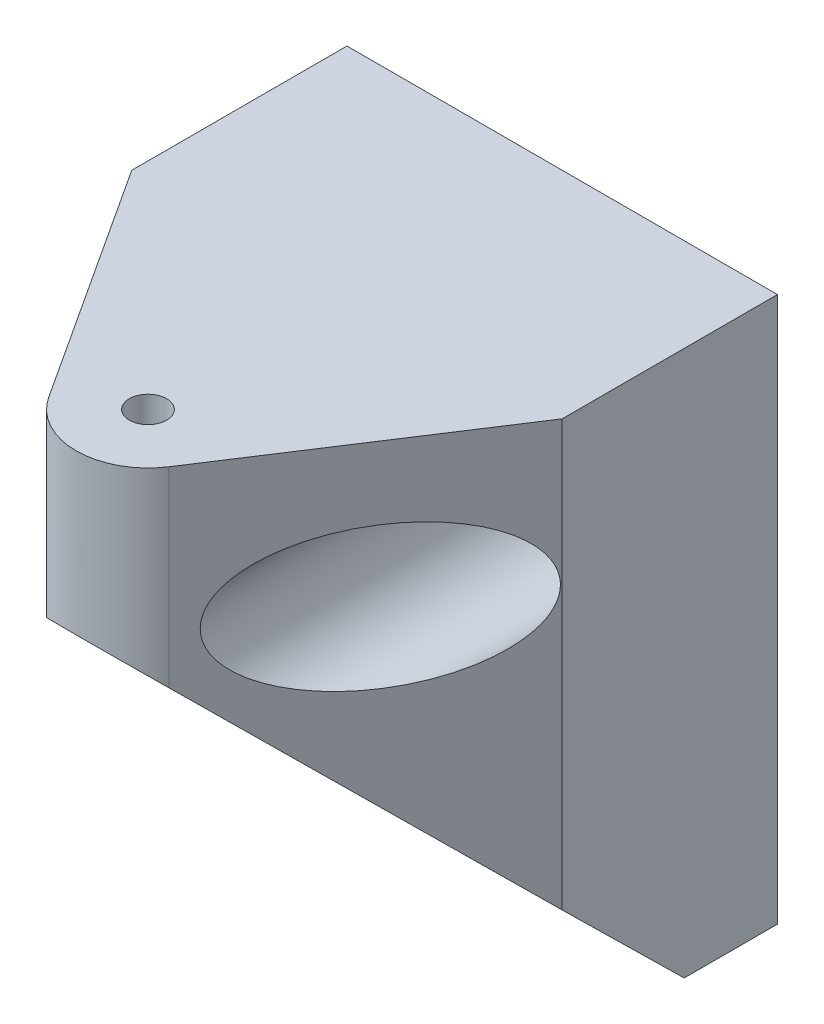
from build123d import *

# Parameters (mm, degrees)
BOSS_EXTRUDE1_DEPTH = 30
CUT_EXTRUDE1_REACH  = 37
SKETCH3_R           = 2.6
CUT_EXTRUDE2_REACH  = 43.5
CUT_EXTRUDE2_START  = -6.5
SKETCH4_R           = 4.95
CUT_EXTRUDE3_REACH  = 40
SKETCH5_R           = 1.3
CUT_EXTRUDE4_REACH  = 40


with BuildPart() as part:
    # Sketch2 → Boss-Extrude1 (new body)
    with BuildSketch(Plane(origin=(0, 0, 0), x_dir=(0, 0, -1), z_dir=(1, 0, 0))):
        Polygon((0, 0), (-6.5, 0), (-35, 28), (-35, 38), (0, 38), align=None)
    extrude(amount=BOSS_EXTRUDE1_DEPTH)

    # Sketch3 → Cut-Extrude1 (cut, up to next)
    with BuildSketch(Plane(origin=(0, 0, 0), x_dir=(-1, 0, 0), z_dir=(0, 0, -1)), mode=Mode.PRIVATE) as cut_extrude1_sk1:
        with Locations((-25, 28)):
            Circle(SKETCH3_R)
    cut_extrude1_tool1 = extrude(cut_extrude1_sk1.sketch, amount=-CUT_EXTRUDE1_REACH, mode=Mode.PRIVATE) & part.part
    add(cut_extrude1_tool1.solids().sort_by_distance((25, 28, 0))[0], mode=Mode.SUBTRACT)
    # Sketch3 → Cut-Extrude1 (cut, up to next)
    with BuildSketch(Plane(origin=(0, 0, 0), x_dir=(-1, 0, 0), z_dir=(0, 0, -1)), mode=Mode.PRIVATE) as cut_extrude1_sk2:
        with Locations((-5, 28)):
            Circle(SKETCH3_R)
    cut_extrude1_tool2 = extrude(cut_extrude1_sk2.sketch, amount=-CUT_EXTRUDE1_REACH, mode=Mode.PRIVATE) & part.part
    add(cut_extrude1_tool2.solids().sort_by_distance((5, 28, 0))[0], mode=Mode.SUBTRACT)

    # Sketch4 → Cut-Extrude2 (cut, up to next)
    with BuildSketch(Plane(origin=(0, 0, 0), x_dir=(-1, 0, 0), z_dir=(0, 0, -1)).offset(CUT_EXTRUDE2_START), mode=Mode.PRIVATE) as cut_extrude2_sk1:
        with Locations((-25, 28)):
            Circle(SKETCH4_R)
    cut_extrude2_tool1 = extrude(cut_extrude2_sk1.sketch, amount=-CUT_EXTRUDE2_REACH, mode=Mode.PRIVATE) & part.part
    add(cut_extrude2_tool1.solids().sort_by_distance((25, 28, 6.5))[0], mode=Mode.SUBTRACT)
    # Sketch4 → Cut-Extrude2 (cut, up to next)
    with BuildSketch(Plane(origin=(0, 0, 0), x_dir=(-1, 0, 0), z_dir=(0, 0, -1)).offset(CUT_EXTRUDE2_START), mode=Mode.PRIVATE) as cut_extrude2_sk2:
        with Locations((-5, 28)):
            Circle(SKETCH4_R)
    cut_extrude2_tool2 = extrude(cut_extrude2_sk2.sketch, amount=-CUT_EXTRUDE2_REACH, mode=Mode.PRIVATE) & part.part
    add(cut_extrude2_tool2.solids().sort_by_distance((5, 28, 6.5))[0], mode=Mode.SUBTRACT)

    # Sketch5 → Cut-Extrude3 (cut, up to next)
    with BuildSketch(Plane(origin=(0, 38, 0), x_dir=(1, 0, 0), z_dir=(0, 1, 0)), mode=Mode.PRIVATE) as cut_extrude3_sk1:
        with Locations((15, -28.87)):
            Circle(SKETCH5_R)
    cut_extrude3_tool1 = extrude(cut_extrude3_sk1.sketch, amount=-CUT_EXTRUDE3_REACH, mode=Mode.PRIVATE) & part.part
    add(cut_extrude3_tool1.solids().sort_by_distance((15, 38, 28.87))[0], mode=Mode.SUBTRACT)

    # Sketch6 → Cut-Extrude4 (cut, up to next)
    with BuildSketch(Plane(origin=(0, 38, 0), x_dir=(1, 0, 0), z_dir=(0, 1, 0)), mode=Mode.PRIVATE) as cut_extrude4_sk1:
        with BuildLine():
            Line((0, -35), (30, -35))
            Line((30, -35), (30, -15))
            Line((30, -15), (19.189785955, -31.598679836))
            ThreePointArc((19.189785955, -31.598679836), (15, -33.87), (10.810214045, -31.598679836))
            Line((10.810214045, -31.598679836), (0, -15))
            Line((0, -15), (0, -35))
        make_face()
    cut_extrude4_tool1 = extrude(cut_extrude4_sk1.sketch, amount=-CUT_EXTRUDE4_REACH, mode=Mode.PRIVATE) & part.part
    add(cut_extrude4_tool1.solids().sort_by_distance((15, 38, 34.639445))[0], mode=Mode.SUBTRACT)


solid = part.part
